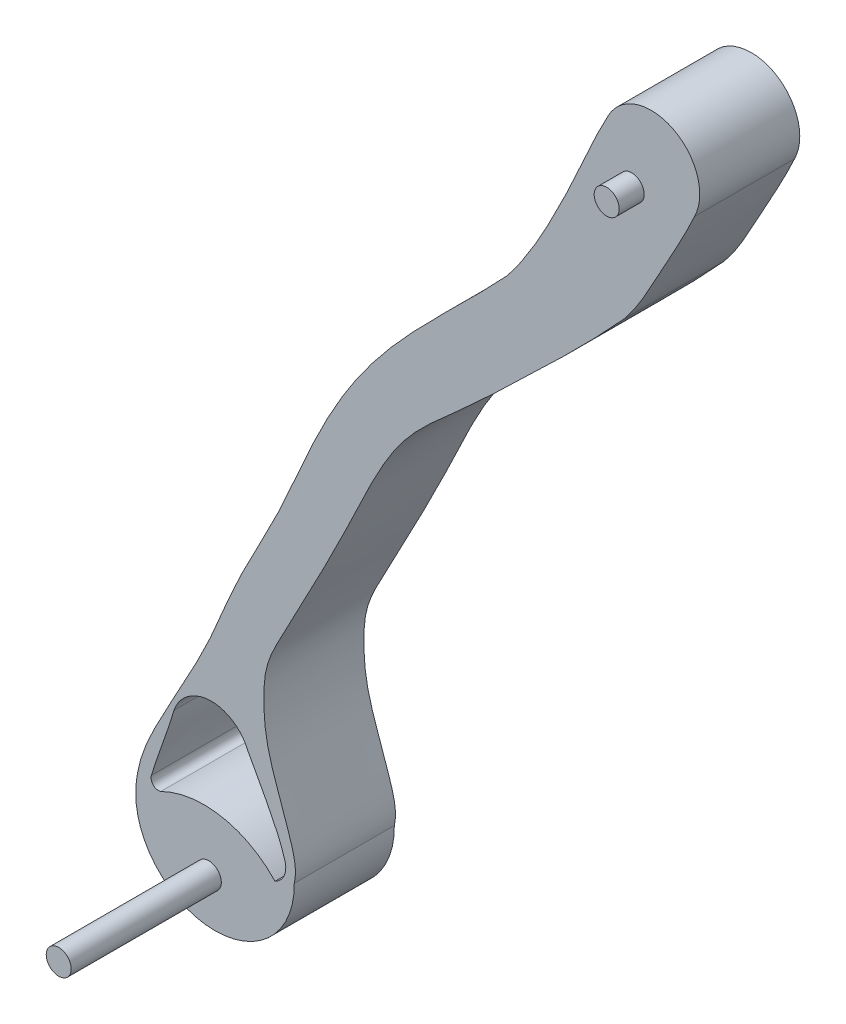
from build123d import *

# Parameters (mm, degrees)
BOSS_EXTRUDE1_DEPTH = 40
SKETCH3_R           = 5
BOSS_EXTRUDE3_DEPTH = 10
CUT_EXTRUDE1_DEPTH  = 40
BOSS_EXTRUDE6_START = -50
SKETCH3_2_R         = 5
BOSS_EXTRUDE6_DEPTH = 50
SKETCH4_R           = 5
BOSS_EXTRUDE7_DEPTH = 60


with BuildPart() as part:
    # Sketch1 → Boss-Extrude1 (new body)
    with BuildSketch(Plane.XY):
        with BuildLine():
            ThreePointArc((-128.435303347, -140.896902453), (-96.755149526, -173.125351057), (-65.074995705, -140.896902453))
            add(Edge.make_bspline(
                [(-65.074995705, -140.896902453), (-63.907652097, -135.87464552), (-66.35100912, -126.659238679), (-71.697657005, -112.128089654), (-76.334712316, -98.472209398), (-77.541709446, -84.207198732), (-76.961960819, -70.342092539), (-68.88579276, -55.69495944), (-58.213845257, -35.305524849), (-45.109839414, -10.285325139), (-33.851241856, 14.939291119), (-19.441261208, 38.761764832), (0.34611134, 54.846253057), (30.149690797, 83.353080433), (52.005250373, 104.155990976), (66.875865875, 120.550338304)],
                knots=[0, 0, 0, 0, 0.04686952, 0.090141713, 0.148581226, 0.183456914, 0.226900489, 0.278590854, 0.340349479, 0.448130788, 0.547901997, 0.604794059, 0.712230619, 0.788345355, 1, 1, 1, 1], degree=3))
            add(Edge.make_bspline(
                [(66.875865875, 120.550338304), (72.386556563, 127.19913785), (81.101735437, 144.070801532), (90.587580648, 160.476032838), (94.896483447, 169.931016127)],
                knots=[0, 0, 0, 0, 0.452321954, 1, 1, 1, 1], degree=3))
            ThreePointArc((94.896483447, 169.931016127), (86.447657386, 195.991479609), (60.387193905, 187.542653548))
            add(Edge.make_bspline(
                [(19.939027909, 111.952234191), (26.24809298, 119.800552758), (36.071780336, 136.393112866), (48.541442057, 162.180154607), (55.829036332, 179.301734236), (60.387193905, 187.542653548)],
                knots=[0, 0, 0, 0, 0.350645712, 0.671542658, 1, 1, 1, 1], degree=3))
            add(Edge.make_bspline(
                [(19.939027909, 111.952234191), (3.65232557, 94.329038748), (-20.249605672, 73.621931367), (-45.652429062, 39.041142074), (-58.842646897, 13.609703306), (-71.789487323, -18.071990564), (-87.738861669, -45.500334261), (-100.863433523, -79.921354986), (-115.452059141, -103.788445803), (-126.143907942, -125.769991297), (-128.340182149, -135.353702394), (-128.435303347, -140.896902453)],
                knots=[0, 0, 0, 0, 0.227860936, 0.297082932, 0.405625713, 0.498415505, 0.621398378, 0.705377541, 0.846798383, 0.88536092, 0.937345032, 0.937345032, 0.937345032, 0.937345032], degree=3))
        make_face()
    extrude(amount=BOSS_EXTRUDE1_DEPTH)

    # Sketch3 → Boss-Extrude3 (add)
    with BuildSketch(Plane.XY.offset(40)):
        with Locations((69.819387709, 167.582956348)):
            Circle(SKETCH3_R)
    extrude(amount=BOSS_EXTRUDE3_DEPTH)

    # Sketch2 → Cut-Extrude1 (cut)
    with BuildSketch(Plane(origin=(0, 0, 0), x_dir=(-1, 0, 0), z_dir=(0, 0, -1))):
        with BuildLine():
            ThreePointArc((68.756079477, -135.101198343), (69.135093574, -140.284053245), (72.767176325, -144.000719965))
            ThreePointArc((72.767176325, -144.000719965), (94.214636305, -132.290590151), (118.40985459, -135.71288353))
            ThreePointArc((118.40985459, -135.71288353), (121.480604985, -135.007019726), (122.117435387, -131.921213715))
            add(Edge.make_bspline(
                [(122.117435387, -131.921213715), (121.902241698, -131.121274345), (121.440830196, -129.570265663), (120.671868024, -127.192672605), (119.652569307, -124.170271778), (118.304661288, -120.363805326), (116.083389287, -114.1940152), (114.313518517, -109.046051235), (113.271974893, -105.380725172), (113.174364562, -105.029678695)],
                knots=[0.036199993, 0.036199993, 0.036199993, 0.036199993, 0.044998375, 0.052823255, 0.060648134, 0.076297892, 0.091947651, 0.123247168, 0.126550229, 0.126550229, 0.126550229, 0.126550229], degree=3))
            ThreePointArc((113.174364562, -105.029678695), (98.834885933, -94.391617828), (83.767621929, -103.971103295))
            add(Edge.make_bspline(
                [(83.767621929, -103.971103295), (83.587351822, -104.298739766), (81.914012514, -107.339065994), (79.505680761, -111.713780784), (76.624782808, -117.103856723), (74.514987608, -121.165521306), (72.523371571, -125.181904734), (70.751114993, -129.17446861), (69.536178497, -132.477867128), (68.933551478, -134.470064331), (68.756079477, -135.101198343)],
                knots=[0.787262055, 0.787262055, 0.787262055, 0.787262055, 0.790799641, 0.820108719, 0.834763258, 0.849417797, 0.864072336, 0.878726875, 0.893381414, 0.900142659, 0.900142659, 0.900142659, 0.900142659], degree=3))
        make_face()
    extrude(amount=-CUT_EXTRUDE1_DEPTH, mode=Mode.SUBTRACT)

    # Sketch3_2 → Boss-Extrude6 (add)
    with BuildSketch(Plane.XY.offset(40).offset(BOSS_EXTRUDE6_START)):
        with Locations((69.819387709, 167.582956348)):
            Circle(SKETCH3_2_R)
    extrude(amount=BOSS_EXTRUDE6_DEPTH)

    # Sketch4 → Boss-Extrude7 (add)
    with BuildSketch(Plane.XY.offset(40)):
        with Locations((-99.230093204, -155.129512749)):
            Circle(SKETCH4_R)
    extrude(amount=BOSS_EXTRUDE7_DEPTH)


solid = part.part
